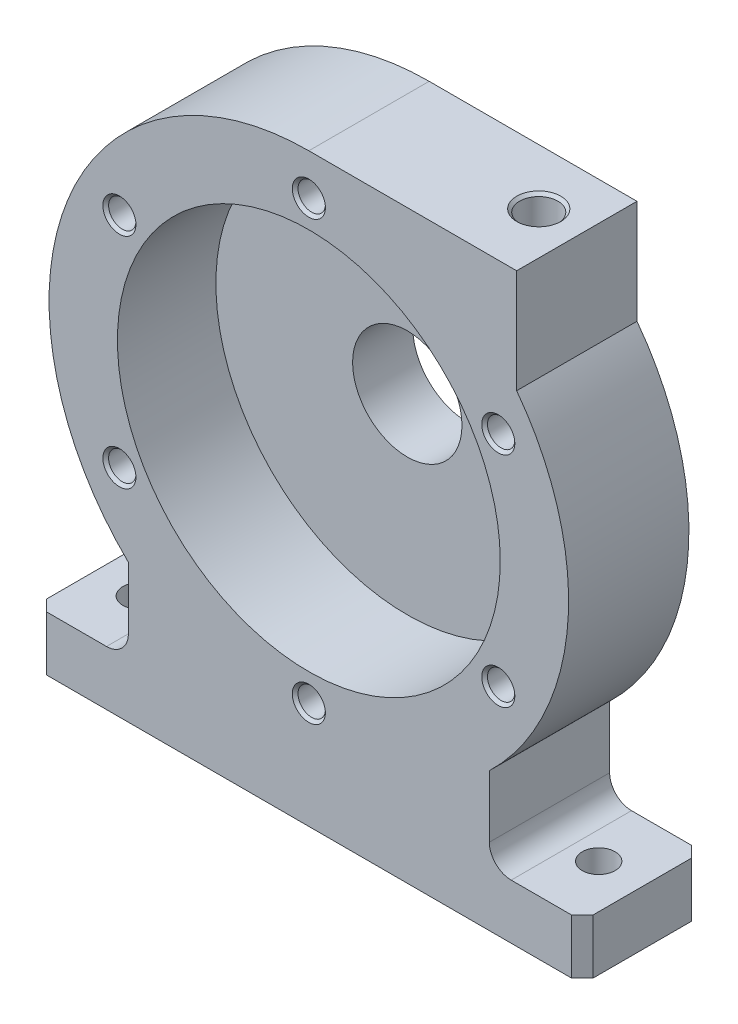
from build123d import *

# Parameters (mm, degrees)
BOSS_EXTRUDE2_DEPTH                                 = 22
SKETCH6_R                                           = 35
CUT_EXTRUDE2_DEPTH                                  = 18
CHAMFER2_SIZE                                       = 2
CIRPATTERN2_COUNT                                   = 6
M8X1_0_TAPPED_HOLE1_D                               = 7
M8X1_0_TAPPED_HOLE1_DEPTH                           = 15
M8X1_0_TAPPED_HOLE1_CSINK_D                         = 8.05
M8X1_0_TAPPED_HOLE1_CSINK_ANGLE                     = 90
M8X1_0_TAPPED_HOLE1_TIP                             = 2.103012167
CSK_FOR_M8_COUNTERSUNK_FLAT_HEAD_SCREW1_D           = 6
CSK_FOR_M8_COUNTERSUNK_FLAT_HEAD_SCREW1_DEPTH       = 20
CSK_FOR_M8_COUNTERSUNK_FLAT_HEAD_SCREW1_CSINK_D     = 8
CSK_FOR_M8_COUNTERSUNK_FLAT_HEAD_SCREW1_CSINK_ANGLE = 90
CSK_FOR_M8_COUNTERSUNK_FLAT_HEAD_SCREW1_TIP         = 1.802581857
SKETCH15_R                                          = 14
BOSS_EXTRUDE3_DEPTH                                 = 7
FILLET1_R                                           = 4
SKETCH16_R                                          = 10
CUT_EXTRUDE3_DEPTH                                  = 30


with BuildPart() as part:
    # Sketch1 → Boss-Extrude2 (new body)
    with BuildSketch(Plane.XY):
        with BuildLine():
            Line((0, 47.5), (38, 47.5))
            Line((38, 47.5), (38, 28.5))
            ThreePointArc((38, 28.5), (47.349517724, -3.777985082), (33, -34.165040612))
            Line((33, -34.165040612), (33, -45.5))
            ThreePointArc((33, -45.5), (34.171572875, -48.328427125), (37, -49.5))
            Line((37, -49.5), (50, -49.5))
            Line((50, -49.5), (50, -59.5))
            Line((50, -59.5), (-50, -59.5))
            Line((-50, -59.5), (-50, -49.5))
            Line((-50, -49.5), (-37, -49.5))
            ThreePointArc((-37, -49.5), (-34.171572875, -48.328427125), (-33, -45.5))
            Line((-33, -45.5), (-33, -34.165040612))
            ThreePointArc((-33, -34.165040612), (-44.040262426, 17.796215482), (0, 47.5))
        make_face()
    extrude(amount=BOSS_EXTRUDE2_DEPTH)

    # Sketch6 → Cut-Extrude2 (cut)
    with BuildSketch(Plane.XY.offset(22)):
        Circle(SKETCH6_R)
    extrude(amount=-CUT_EXTRUDE2_DEPTH, mode=Mode.SUBTRACT)

    # Chamfer2
    chamfer2_edges = [part.edges().sort_by_distance(p)[0] for p in [
        (50, -54.5, 0),
        (-50, -54.5, 0),
        (-50, -54.5, 22),
        (50, -54.5, 22),
    ]]
    chamfer(chamfer2_edges, length=CHAMFER2_SIZE)

    # Sketch8 → M6 Tapped Hole2 (revolve, cut)
    with BuildSketch(Plane(origin=(0, 40, 22), x_dir=(0, -1, 0), z_dir=(1, 0, 0))):
        Polygon((0, 0), (0, 18.502151548), (2.5, 17), (2.5, 0.525), (3.025, 0), align=None)
    m6_tapped_hole2 = revolve(axis=Axis((0, 40, 28.35), (0, 0, -1)), mode=Mode.SUBTRACT)

    # CirPattern2: M6 Tapped Hole2 ×6 about axis
    cirpattern2_axis = Axis((0, 0, 0), (0, 0, 1))
    for i in range(1, CIRPATTERN2_COUNT):
        add(m6_tapped_hole2.rotate(cirpattern2_axis, i * 360 / CIRPATTERN2_COUNT), mode=Mode.SUBTRACT)

    # M8x1.0 Tapped Hole1
    with Locations(Plane(origin=(30.22, 47.5, 10.178935138), x_dir=(0, 0, 1), z_dir=(0, 1, 0))):
        with Locations((0, 0)):
            CounterSinkHole(M8X1_0_TAPPED_HOLE1_D / 2, M8X1_0_TAPPED_HOLE1_CSINK_D / 2, depth=M8X1_0_TAPPED_HOLE1_DEPTH, counter_sink_angle=M8X1_0_TAPPED_HOLE1_CSINK_ANGLE)
            with Locations((0, 0, -(M8X1_0_TAPPED_HOLE1_DEPTH + M8X1_0_TAPPED_HOLE1_TIP / 2))):  # 118° drill point
                Cone(0, M8X1_0_TAPPED_HOLE1_D / 2, M8X1_0_TAPPED_HOLE1_TIP, mode=Mode.SUBTRACT)

    # CSK for M8 Countersunk Flat Head Screw1
    with Locations(Plane(origin=(-42, -59.5, 11), x_dir=(-1, 0, 0), z_dir=(0, -1, 0))):
        with Locations((0, 0), (-84, 0)):
            CounterSinkHole(CSK_FOR_M8_COUNTERSUNK_FLAT_HEAD_SCREW1_D / 2, CSK_FOR_M8_COUNTERSUNK_FLAT_HEAD_SCREW1_CSINK_D / 2, depth=CSK_FOR_M8_COUNTERSUNK_FLAT_HEAD_SCREW1_DEPTH, counter_sink_angle=CSK_FOR_M8_COUNTERSUNK_FLAT_HEAD_SCREW1_CSINK_ANGLE)
            with Locations((0, 0, -(CSK_FOR_M8_COUNTERSUNK_FLAT_HEAD_SCREW1_DEPTH + CSK_FOR_M8_COUNTERSUNK_FLAT_HEAD_SCREW1_TIP / 2))):  # 118° drill point
                Cone(0, CSK_FOR_M8_COUNTERSUNK_FLAT_HEAD_SCREW1_D / 2, CSK_FOR_M8_COUNTERSUNK_FLAT_HEAD_SCREW1_TIP, mode=Mode.SUBTRACT)

    # Sketch15 → Boss-Extrude3 (add)
    with BuildSketch(Plane(origin=(0, 0, 0), x_dir=(-1, 0, 0), z_dir=(0, 0, -1))):
        Circle(SKETCH15_R)
    extrude(amount=BOSS_EXTRUDE3_DEPTH)

    # Fillet1
    fillet1_edges = [part.edges().sort_by_distance(p)[0] for p in [
        (14, 0, 0),
    ]]
    fillet(fillet1_edges, radius=FILLET1_R)

    # Sketch16 → Cut-Extrude3 (cut, through all)
    with BuildSketch(Plane(origin=(0, 0, -7), x_dir=(-1, 0, 0), z_dir=(0, 0, -1))):
        Circle(SKETCH16_R)
    extrude(amount=-CUT_EXTRUDE3_DEPTH, mode=Mode.SUBTRACT)


solid = part.part
